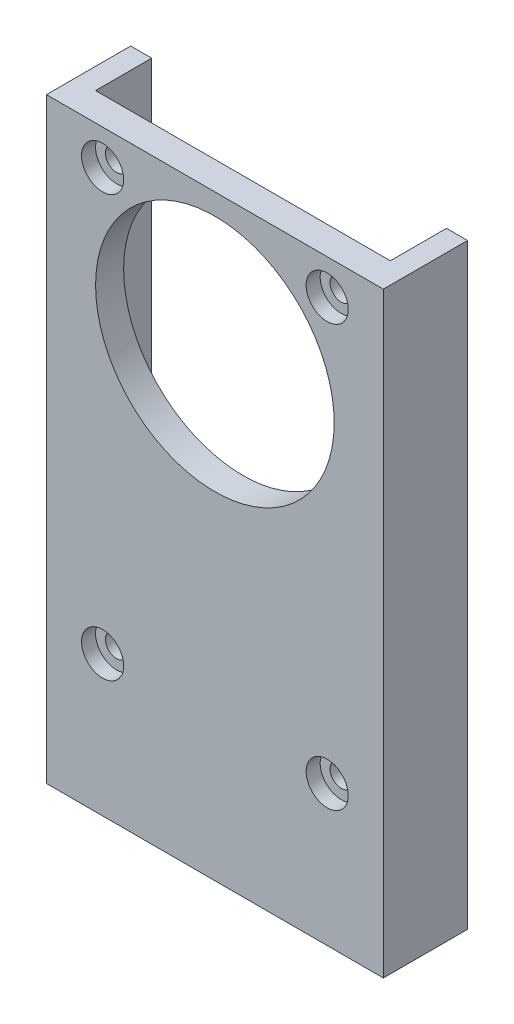
from build123d import *

# Parameters (mm, degrees)
SKETCH1_W                  = 21
SKETCH1_H                  = 35
SKETCH1_R                  = 0.8
SKETCH1_R_2                = 8.5
BRACKETWITHBOLTHOLES_DEPTH = 2
SKETCH2_W                  = 10
SKETCH2_H                  = 2
BRACKETEXTENSION_DEPTH     = 2
SKETCH2_3_W                = 10
SKETCH2_3_H                = 2
BASE_DEPTH                 = 7.5
SKETCH3_R                  = 1
BASEBOLTHOLE_DEPTH         = 3
BASENUTSLOT_DEPTH          = 1
STIFFENERRIB_DEPTH         = 42.5
SKETCH5_R                  = 1.5
BOLTHATSLOTS_DEPTH         = 1


with BuildPart() as part:
    # Sketch1 → BracketWithBoltHoles (new body)
    with BuildSketch(Plane.XY):
        Rectangle(SKETCH1_W, SKETCH1_H)
        with Locations((-8, 15)):
            Circle(SKETCH1_R, mode=Mode.SUBTRACT)
        with Locations((8, 15)):
            Circle(SKETCH1_R, mode=Mode.SUBTRACT)
        with Locations((8, -15)):
            Circle(SKETCH1_R, mode=Mode.SUBTRACT)
        with Locations((-8, -15)):
            Circle(SKETCH1_R, mode=Mode.SUBTRACT)
        with Locations((0, 7.5)):
            Circle(SKETCH1_R_2, mode=Mode.SUBTRACT)
    extrude(amount=BRACKETWITHBOLTHOLES_DEPTH)

    # Sketch2 → BracketExtension (add)
    with BuildSketch(Plane.XY.offset(2)):
        Polygon((10.5, -17.5), (-10.5, -17.5), (-10.5, -25), (-5, -25), (-5, -23), (5, -23), (5, -25), (10.5, -25), align=None)
        with Locations((0, -24)):
            Rectangle(SKETCH2_W, SKETCH2_H)
    extrude(amount=-BRACKETEXTENSION_DEPTH)

    # Sketch2_3 → Base (add)
    with BuildSketch(Plane.XY.offset(2)):
        with Locations((0, -24)):
            Rectangle(SKETCH2_3_W, SKETCH2_3_H)
    extrude(amount=-BASE_DEPTH)

    # Sketch3 → BaseBoltHole (cut, through all)
    with BuildSketch(Plane(origin=(0, -23, 0), x_dir=(1, 0, 0), z_dir=(0, 1, 0))):
        with Locations((0, 2.75)):
            Circle(SKETCH3_R)
    extrude(amount=-BASEBOLTHOLE_DEPTH, mode=Mode.SUBTRACT)

    # Sketch3_3 → BaseNutSlot (cut)
    with BuildSketch(Plane(origin=(0, -23, 0), x_dir=(1, 0, 0), z_dir=(0, 1, 0))):
        Polygon((2.309401077, 2.75), (1.154700538, 4.75), (-1.154700538, 4.75), (-2.309401077, 2.75), (-1.154700538, 0.75), (1.154700538, 0.75), align=None)
    extrude(amount=-BASENUTSLOT_DEPTH, mode=Mode.SUBTRACT)

    # Sketch4 → StiffenerRib (add)
    with BuildSketch(Plane(origin=(0, 17.5, 0), x_dir=(1, 0, 0), z_dir=(0, 1, 0))):
        Polygon((-10.5, 4), (-12, 4), (-12, -2), (-10.5, -2), (-10.5, 0), align=None)
    stiffenerrib = extrude(amount=-STIFFENERRIB_DEPTH)

    # StiffenerRib2: StiffenerRib across plane
    add(stiffenerrib.mirror(Plane(origin=(0, 0, 0), x_dir=(0, 0, 1), z_dir=(1, 0, 0))))

    # Sketch5 → BoltHatSlots (cut)
    with BuildSketch(Plane.XY.offset(2)):
        with Locations((8, 15)):
            Circle(SKETCH5_R)
        with Locations((8, -15)):
            Circle(SKETCH5_R)
        with Locations((-8, -15)):
            Circle(SKETCH5_R)
        with Locations((-8, 15)):
            Circle(SKETCH5_R)
    extrude(amount=-BOLTHATSLOTS_DEPTH, mode=Mode.SUBTRACT)


solid = part.part
